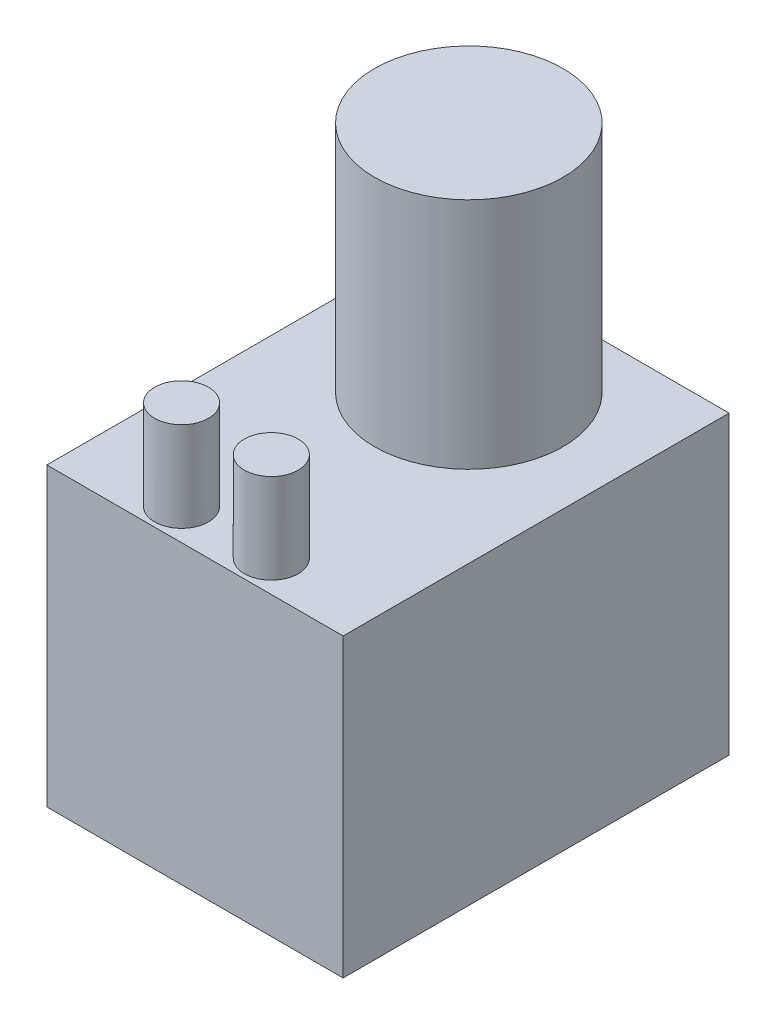
from build123d import *

# Parameters (mm, degrees)
SKETCH_1_W      = 66
SKETCH_1_H      = 66
EXTRUDE_1_DEPTH = 86
SKETCH_2_R      = 21
EXTRUDE_2_DEPTH = 52
SKETCH_3_R      = 6
EXTRUDE_3_DEPTH = 20


with BuildPart() as part:
    # 草图1 → 凸台-拉伸1 (new body)
    with BuildSketch(Plane.XY):
        Rectangle(SKETCH_1_W, SKETCH_1_H)
    extrude(amount=EXTRUDE_1_DEPTH)

    # 草图2 → 凸台-拉伸2 (add)
    with BuildSketch(Plane(origin=(0, 33, 0), x_dir=(1, 0, 0), z_dir=(0, 1, 0))):
        with Locations((0, -25)):
            Circle(SKETCH_2_R)
    extrude(amount=EXTRUDE_2_DEPTH)

    # 草图3 → 凸台-拉伸3 (add)
    with BuildSketch(Plane(origin=(0, 33, 0), x_dir=(1, 0, 0), z_dir=(0, 1, 0))):
        with Locations((-10, -79)):
            Circle(SKETCH_3_R)
        with Locations((10, -79)):
            Circle(SKETCH_3_R)
    extrude(amount=EXTRUDE_3_DEPTH)


solid = part.part
